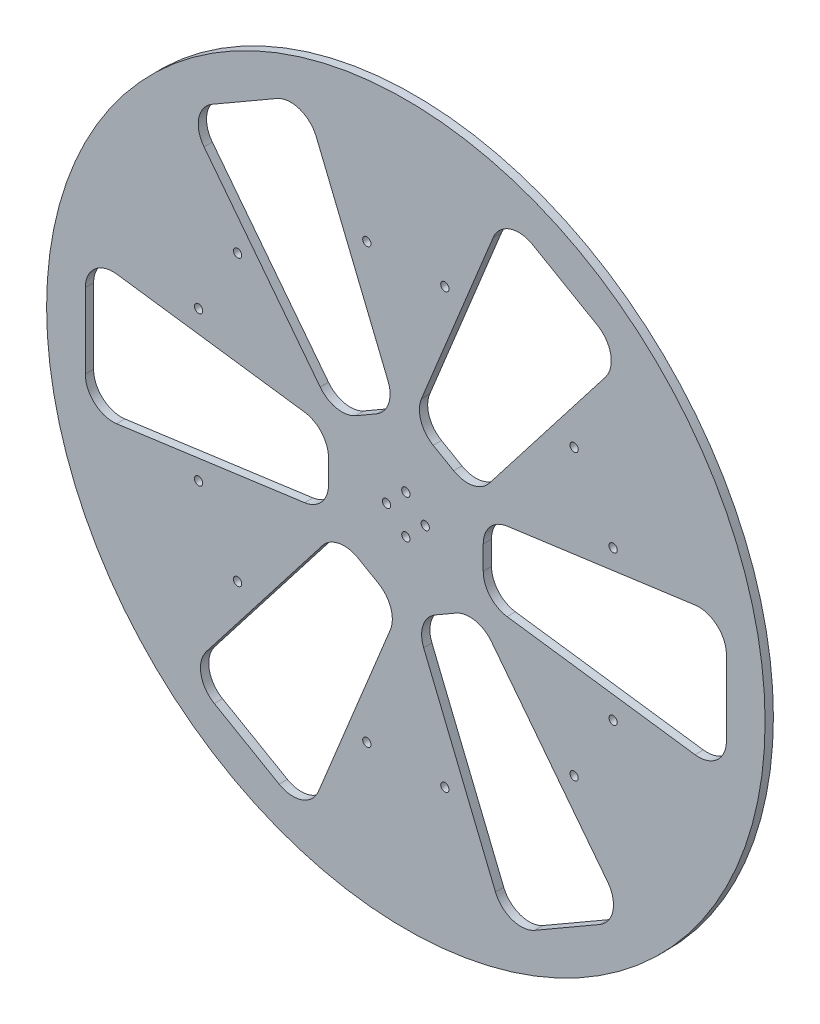
from build123d import *

# Parameters (mm, degrees)
SKETCH_1_R      = 130
SKETCH_1_R_2    = 1.5
EXTRUDE_2_DEPTH = 3


with BuildPart() as part:
    # 草图1 → 凸台-拉伸2 (new body)
    with BuildSketch(Plane.XY):
        Circle(SKETCH_1_R)
        with Locations((-7, 0)):
            Circle(SKETCH_1_R_2, mode=Mode.SUBTRACT)
        with Locations((0, 7)):
            Circle(SKETCH_1_R_2, mode=Mode.SUBTRACT)
        with Locations((7, 0)):
            Circle(SKETCH_1_R_2, mode=Mode.SUBTRACT)
        with Locations((0, -7)):
            Circle(SKETCH_1_R_2, mode=Mode.SUBTRACT)
        with Locations((-75, -27)):
            Circle(SKETCH_1_R_2, mode=Mode.SUBTRACT)
        with Locations((-75, 27)):
            Circle(SKETCH_1_R_2, mode=Mode.SUBTRACT)
        with Locations((-60.882685902, 51.451905284)):
            Circle(SKETCH_1_R_2, mode=Mode.SUBTRACT)
        with Locations((-14.117314098, 78.451905284)):
            Circle(SKETCH_1_R_2, mode=Mode.SUBTRACT)
        with Locations((14.117314098, 78.451905284)):
            Circle(SKETCH_1_R_2, mode=Mode.SUBTRACT)
        with Locations((60.882685902, 51.451905284)):
            Circle(SKETCH_1_R_2, mode=Mode.SUBTRACT)
        with Locations((75, 27)):
            Circle(SKETCH_1_R_2, mode=Mode.SUBTRACT)
        with Locations((75, -27)):
            Circle(SKETCH_1_R_2, mode=Mode.SUBTRACT)
        with Locations((60.882685902, -51.451905284)):
            Circle(SKETCH_1_R_2, mode=Mode.SUBTRACT)
        with Locations((14.117314098, -78.451905284)):
            Circle(SKETCH_1_R_2, mode=Mode.SUBTRACT)
        with Locations((-14.117314098, -78.451905284)):
            Circle(SKETCH_1_R_2, mode=Mode.SUBTRACT)
        with Locations((-60.882685902, -51.451905284)):
            Circle(SKETCH_1_R_2, mode=Mode.SUBTRACT)
        with BuildLine():
            Line((-14.400742953, 24.012884092), (-18.099614878, 21.87733939))
            ThreePointArc((-18.099614878, 21.87733939), (-25.027817426, 20.725252477), (-31.004889818, 24.413327911))
            Line((-31.004889818, 24.413327911), (-73.035307199, 78.666691732))
            ThreePointArc((-73.035307199, 78.666691732), (-74.94237321, 86.719159796), (-70.130032259, 93.451211287))
            Line((-70.130032259, 93.451211287), (-46.671453646, 106.995027963))
            ThreePointArc((-46.671453646, 106.995027963), (-38.435155561, 107.796611733), (-32.415046659, 102.118810089))
            Line((-32.415046659, 102.118810089), (-6.44546404, 38.592718995))
            ThreePointArc((-6.44546404, 38.592718995), (-6.240033219, 31.572384746), (-10.701871027, 26.148428794))
            Line((-10.701871027, 26.148428794), (-14.400742953, 24.012884092))
        make_face(mode=Mode.SUBTRACT)
        with BuildLine():
            Line((-27.996139118, -0.464967184), (-27.996139118, -4.736056588))
            ThreePointArc((-27.996139118, -4.736056588), (-30.462503858, -11.312099453), (-36.645007071, -14.644358269))
            Line((-36.645007071, -14.644358269), (-104.645007071, -23.917085542))
            ThreePointArc((-104.645007071, -23.917085542), (-112.572181983, -21.542419122), (-115.996139118, -14.008783861))
            Line((-115.996139118, -14.008783861), (-115.996139118, 13.078849492))
            ThreePointArc((-115.996139118, 13.078849492), (-112.572181983, 20.612484753), (-104.645007071, 22.987151173))
            Line((-104.645007071, 22.987151173), (-36.645007071, 13.7144239))
            ThreePointArc((-36.645007071, 13.7144239), (-30.462503858, 10.382165085), (-27.996139118, 3.80612222))
            Line((-27.996139118, 3.80612222), (-27.996139118, -0.464967184))
        make_face(mode=Mode.SUBTRACT)
        with BuildLine():
            Line((13.595396165, 24.477851276), (9.89652424, 26.613395978))
            ThreePointArc((9.89652424, 26.613395978), (5.434686432, 32.03735193), (5.640117252, 39.05768618))
            Line((5.640117252, 39.05768618), (31.609699872, 102.583777273))
            ThreePointArc((31.609699872, 102.583777273), (37.629808773, 108.261578918), (45.866106859, 107.459995148))
            Line((45.866106859, 107.459995148), (69.324685472, 93.916178471))
            ThreePointArc((69.324685472, 93.916178471), (74.137026423, 87.18412698), (72.229960412, 79.131658916))
            Line((72.229960412, 79.131658916), (30.199543031, 24.878295095))
            ThreePointArc((30.199543031, 24.878295095), (24.222470638, 21.190219661), (17.294268091, 22.342306574))
            Line((17.294268091, 22.342306574), (13.595396165, 24.477851276))
        make_face(mode=Mode.SUBTRACT)
        with BuildLine():
            Line((27.996139118, 0.464967184), (27.996139118, 4.736056588))
            ThreePointArc((27.996139118, 4.736056588), (30.462503858, 11.312099453), (36.645007071, 14.644358269))
            Line((36.645007071, 14.644358269), (104.645007071, 23.917085542))
            ThreePointArc((104.645007071, 23.917085542), (112.572181983, 21.542419122), (115.996139118, 14.008783861))
            Line((115.996139118, 14.008783861), (115.996139118, -13.078849492))
            ThreePointArc((115.996139118, -13.078849492), (112.572181983, -20.612484753), (104.645007071, -22.987151173))
            Line((104.645007071, -22.987151173), (36.645007071, -13.7144239))
            ThreePointArc((36.645007071, -13.7144239), (30.462503858, -10.382165085), (27.996139118, -3.80612222))
            Line((27.996139118, -3.80612222), (27.996139118, 0.464967184))
        make_face(mode=Mode.SUBTRACT)
        with BuildLine():
            Line((14.400742953, -24.012884092), (18.099614878, -21.87733939))
            ThreePointArc((18.099614878, -21.87733939), (25.027817426, -20.725252477), (31.004889818, -24.413327911))
            Line((31.004889818, -24.413327911), (73.035307199, -78.666691732))
            ThreePointArc((73.035307199, -78.666691732), (74.94237321, -86.719159796), (70.130032259, -93.451211287))
            Line((70.130032259, -93.451211287), (46.671453646, -106.995027963))
            ThreePointArc((46.671453646, -106.995027963), (38.435155561, -107.796611733), (32.415046659, -102.118810089))
            Line((32.415046659, -102.118810089), (6.44546404, -38.592718995))
            ThreePointArc((6.44546404, -38.592718995), (6.240033219, -31.572384746), (10.701871027, -26.148428794))
            Line((10.701871027, -26.148428794), (14.400742953, -24.012884092))
        make_face(mode=Mode.SUBTRACT)
        with BuildLine():
            Line((-13.595396165, -24.477851276), (-9.89652424, -26.613395978))
            ThreePointArc((-9.89652424, -26.613395978), (-5.434686432, -32.03735193), (-5.640117252, -39.05768618))
            Line((-5.640117252, -39.05768618), (-31.609699872, -102.583777273))
            ThreePointArc((-31.609699872, -102.583777273), (-37.629808773, -108.261578918), (-45.866106859, -107.459995148))
            Line((-45.866106859, -107.459995148), (-69.324685472, -93.916178471))
            ThreePointArc((-69.324685472, -93.916178471), (-74.137026423, -87.18412698), (-72.229960412, -79.131658916))
            Line((-72.229960412, -79.131658916), (-30.199543031, -24.878295095))
            ThreePointArc((-30.199543031, -24.878295095), (-24.222470638, -21.190219661), (-17.294268091, -22.342306574))
            Line((-17.294268091, -22.342306574), (-13.595396165, -24.477851276))
        make_face(mode=Mode.SUBTRACT)
    extrude(amount=EXTRUDE_2_DEPTH)


solid = part.part
